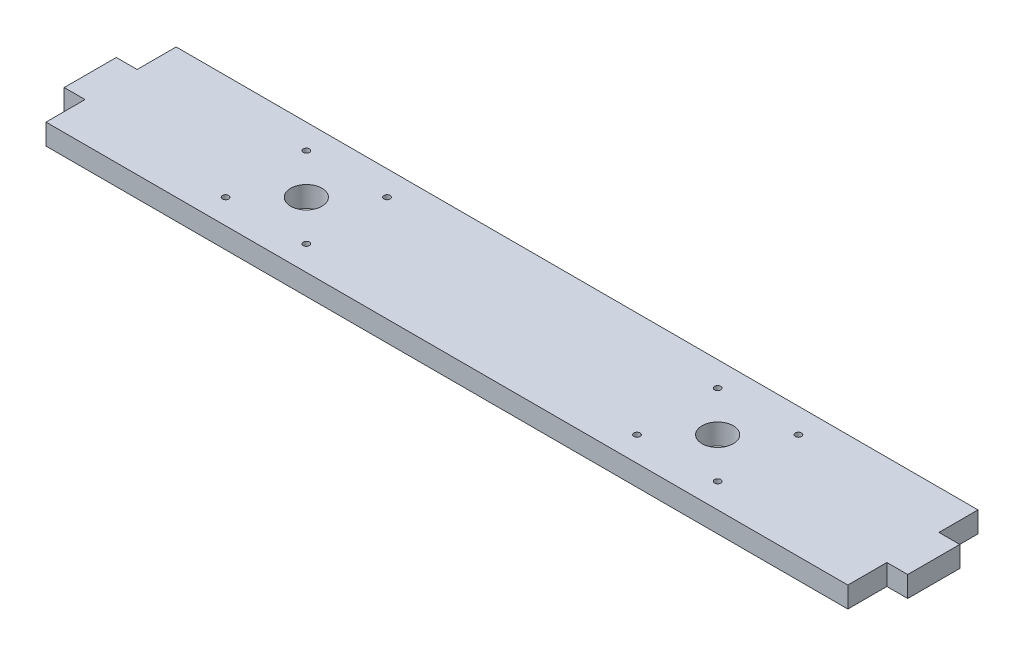
from build123d import *

# Parameters (mm, degrees)
SKETCH1_W           = 308
SKETCH1_H           = 50
SKETCH1_R           = 6
SKETCH1_R_2         = 1.2
BOSS_EXTRUDE1_DEPTH = 8
SKETCH2_W           = 8
SKETCH2_H           = 20
BOSS_EXTRUDE2_DEPTH = 8


with BuildPart() as part:
    # Sketch1 → Boss-Extrude1 (new body)
    with BuildSketch(Plane(origin=(0, 0, 0), x_dir=(1, 0, 0), z_dir=(0, 1, 0))):
        with Locations((154, 25)):
            Rectangle(SKETCH1_W, SKETCH1_H)
        with Locations((75, 25)):
            Circle(SKETCH1_R, mode=Mode.SUBTRACT)
        with Locations((59.5, 40.5)):
            Circle(SKETCH1_R_2, mode=Mode.SUBTRACT)
        with Locations((90.5, 40.5)):
            Circle(SKETCH1_R_2, mode=Mode.SUBTRACT)
        with Locations((59.5, 9.5)):
            Circle(SKETCH1_R_2, mode=Mode.SUBTRACT)
        with Locations((90.5, 9.5)):
            Circle(SKETCH1_R_2, mode=Mode.SUBTRACT)
        with Locations((217.5, 9.5)):
            Circle(SKETCH1_R_2, mode=Mode.SUBTRACT)
        with Locations((248.5, 9.5)):
            Circle(SKETCH1_R_2, mode=Mode.SUBTRACT)
        with Locations((217.5, 40.5)):
            Circle(SKETCH1_R_2, mode=Mode.SUBTRACT)
        with Locations((233, 25)):
            Circle(SKETCH1_R, mode=Mode.SUBTRACT)
        with Locations((248.5, 40.5)):
            Circle(SKETCH1_R_2, mode=Mode.SUBTRACT)
    extrude(amount=BOSS_EXTRUDE1_DEPTH)

    # Sketch2 → Boss-Extrude2 (add)
    with BuildSketch(Plane(origin=(0, 8, 0), x_dir=(-1, 0, 0), z_dir=(0, 1, 0))):
        with Locations((4, -25)):
            Rectangle(SKETCH2_W, SKETCH2_H)
        with Locations((-312, -25)):
            Rectangle(SKETCH2_W, SKETCH2_H)
    extrude(amount=-BOSS_EXTRUDE2_DEPTH)


solid = part.part
